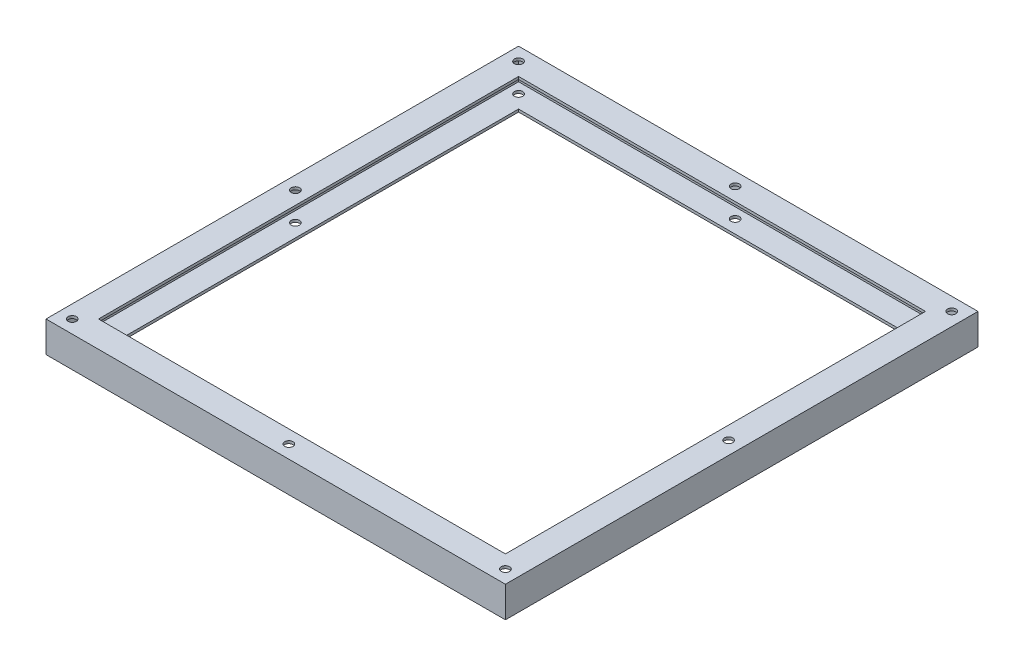
from build123d import *

# Parameters (mm, degrees)
ESQUISSE1_W             = 350
ESQUISSE1_H             = 360
ESQUISSE1_R             = 3.175
ESQUISSE1_W_2           = 310
ESQUISSE1_H_2           = 320
BOSS_EXTRU_2_DEPTH      = 23.5
ENL_V_START             = 2
ESQUISSE1_4_W           = 346
ESQUISSE1_4_H           = 356
ENL_V_MAT_EXTRU_1_DEPTH = 19.5


with BuildPart() as part:
    # Esquisse1 → Boss.-Extru.2 (new body)
    with BuildSketch(Plane(origin=(0, 0, 0), x_dir=(1, 0, 0), z_dir=(0, 1, 0))):
        with Locations((175, 180)):
            Rectangle(ESQUISSE1_W, ESQUISSE1_H)
        with Locations((10, 350)):
            Circle(ESQUISSE1_R, mode=Mode.SUBTRACT)
        with Locations((340, 180)):
            Circle(ESQUISSE1_R, mode=Mode.SUBTRACT)
        with Locations((175, 350)):
            Circle(ESQUISSE1_R, mode=Mode.SUBTRACT)
        with Locations((340, 350)):
            Circle(ESQUISSE1_R, mode=Mode.SUBTRACT)
        with Locations((10, 10)):
            Circle(ESQUISSE1_R, mode=Mode.SUBTRACT)
        with Locations((10, 180)):
            Circle(ESQUISSE1_R, mode=Mode.SUBTRACT)
        with Locations((175, 10)):
            Circle(ESQUISSE1_R, mode=Mode.SUBTRACT)
        with Locations((340, 10)):
            Circle(ESQUISSE1_R, mode=Mode.SUBTRACT)
        with Locations((175, 180)):
            Rectangle(ESQUISSE1_W_2, ESQUISSE1_H_2, mode=Mode.SUBTRACT)
    extrude(amount=BOSS_EXTRU_2_DEPTH)

    # Esquisse1_4 → Enl_v. mat.-Extru.1 (cut)
    with BuildSketch(Plane(origin=(0, 0, 0), x_dir=(1, 0, 0), z_dir=(0, 1, 0)).offset(ENL_V_START)):
        with Locations((175, 180)):
            Rectangle(ESQUISSE1_4_W, ESQUISSE1_4_H)
    extrude(amount=ENL_V_MAT_EXTRU_1_DEPTH, mode=Mode.SUBTRACT)


solid = part.part
